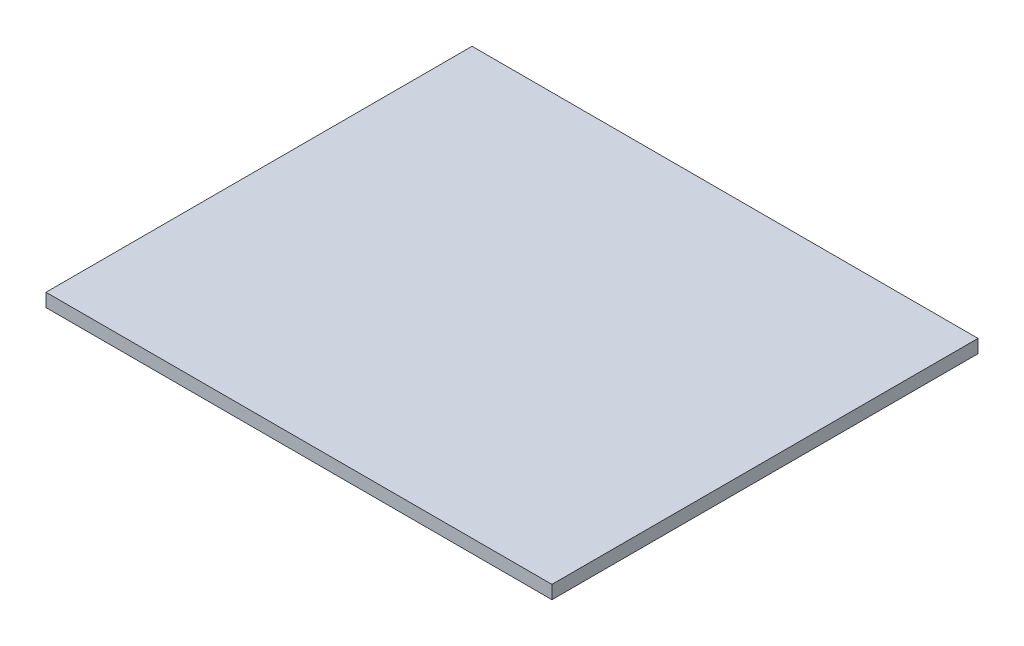
from build123d import *

# Parameters (mm, degrees)
BOSS_EXTRUDE1_DEPTH = 1


with BuildPart() as part:
    # Sketch1 → Boss-Extrude1 (new body)
    with BuildSketch(Plane(origin=(0, 0, 0), x_dir=(1, 0, 0), z_dir=(0, 1, 0))):
        Polygon((0, 9.65), (0, 0), (38, 0), (38, 32), (0, 32), (0, 22.15), (0, 18.307380305), align=None)
    extrude(amount=BOSS_EXTRUDE1_DEPTH)


solid = part.part
